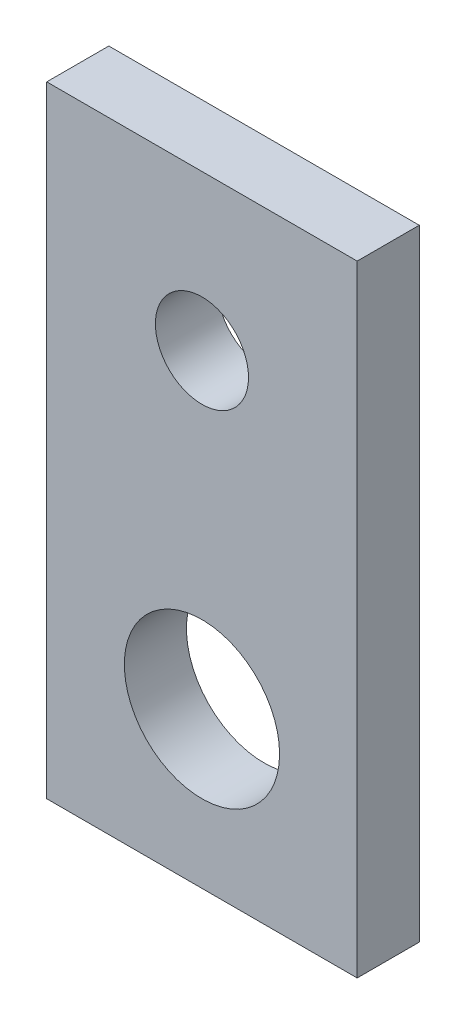
from build123d import *

# Parameters (mm, degrees)
ESQUISSE1_W        = 10
ESQUISSE1_H        = 20
ESQUISSE1_R        = 1.5
ESQUISSE1_R_2      = 2.5
BOSS_EXTRU_1_DEPTH = 2


with BuildPart() as part:
    # Esquisse1 → Boss.-Extru.1 (new body)
    with BuildSketch(Plane.XY):
        with Locations((-5, 0)):
            Rectangle(ESQUISSE1_W, ESQUISSE1_H)
        with Locations((-5, 5.002591016)):
            Circle(ESQUISSE1_R, mode=Mode.SUBTRACT)
        with Locations((-5, -5)):
            Circle(ESQUISSE1_R_2, mode=Mode.SUBTRACT)
    extrude(amount=BOSS_EXTRU_1_DEPTH)


solid = part.part
